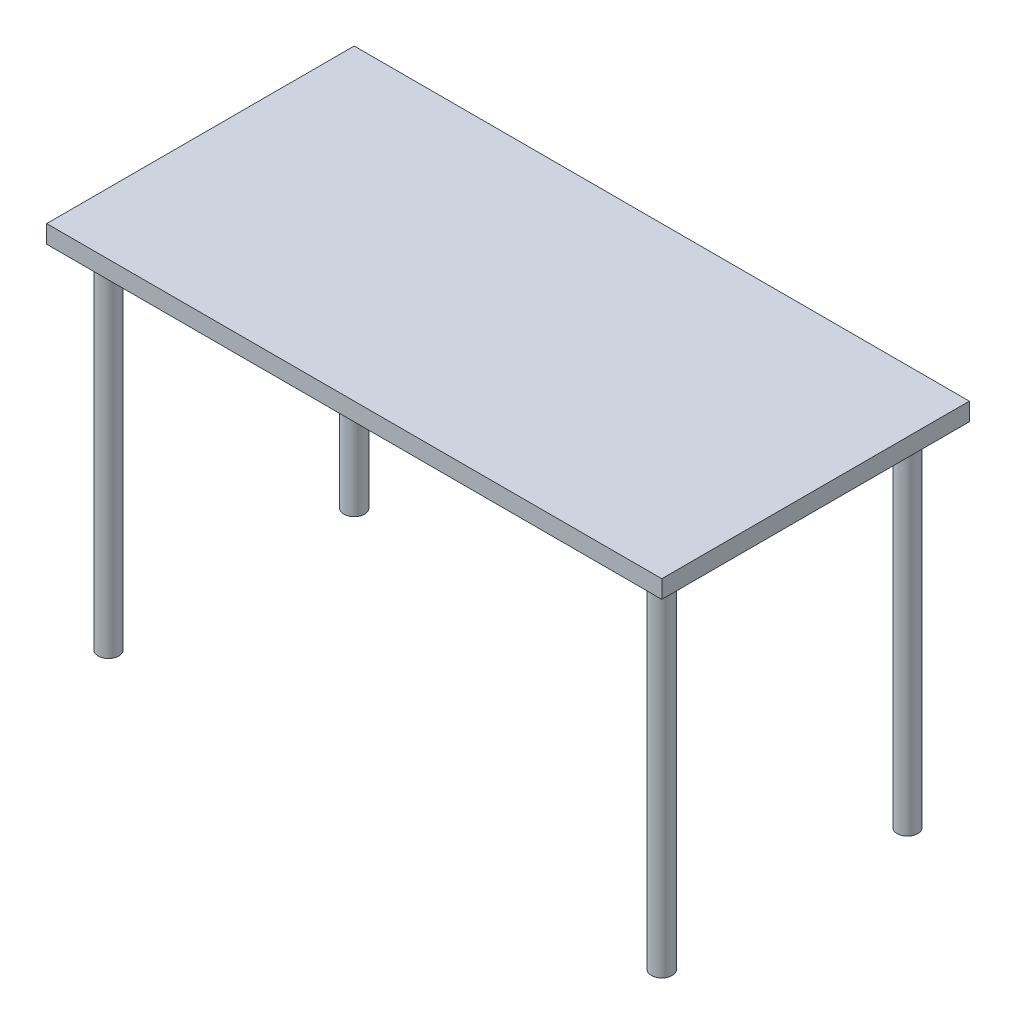
from build123d import *

# Parameters (mm, degrees)
SKETCH1_W           = 1200.15
SKETCH1_H           = 600.075
BOSS_EXTRUDE1_DEPTH = 34.925
SKETCH2_R           = 20.213000011
BOSS_EXTRUDE2_DEPTH = 685.8
SKETCH3_R           = 51.963000011
BOSS_EXTRUDE3_DEPTH = 1.5875


with BuildPart() as part:
    # Sketch1 → Boss-Extrude1 (new body)
    with BuildSketch(Plane(origin=(0, 0, 0), x_dir=(1, 0, 0), z_dir=(0, 1, 0))):
        Rectangle(SKETCH1_W, SKETCH1_H)
    extrude(amount=BOSS_EXTRUDE1_DEPTH)

    # Sketch2 → Boss-Extrude2 (add)
    with BuildSketch(Plane.XZ):
        with Locations((-539.75, 239.7125)):
            Circle(SKETCH2_R)
        with Locations((539.75, 239.7125)):
            Circle(SKETCH2_R)
        with Locations((-539.75, -239.7125)):
            Circle(SKETCH2_R)
        with Locations((539.75, -239.7125)):
            Circle(SKETCH2_R)
    extrude(amount=BOSS_EXTRUDE2_DEPTH)

    # Sketch3 → Boss-Extrude3 (add)
    with BuildSketch(Plane.XZ):
        with Locations((-539.75, 239.7125)):
            Circle(SKETCH3_R)
        with Locations((539.75, 239.7125)):
            Circle(SKETCH3_R)
        with Locations((539.75, -239.7125)):
            Circle(SKETCH3_R)
        with Locations((-539.75, -239.7125)):
            Circle(SKETCH3_R)
    extrude(amount=BOSS_EXTRUDE3_DEPTH)


solid = part.part
